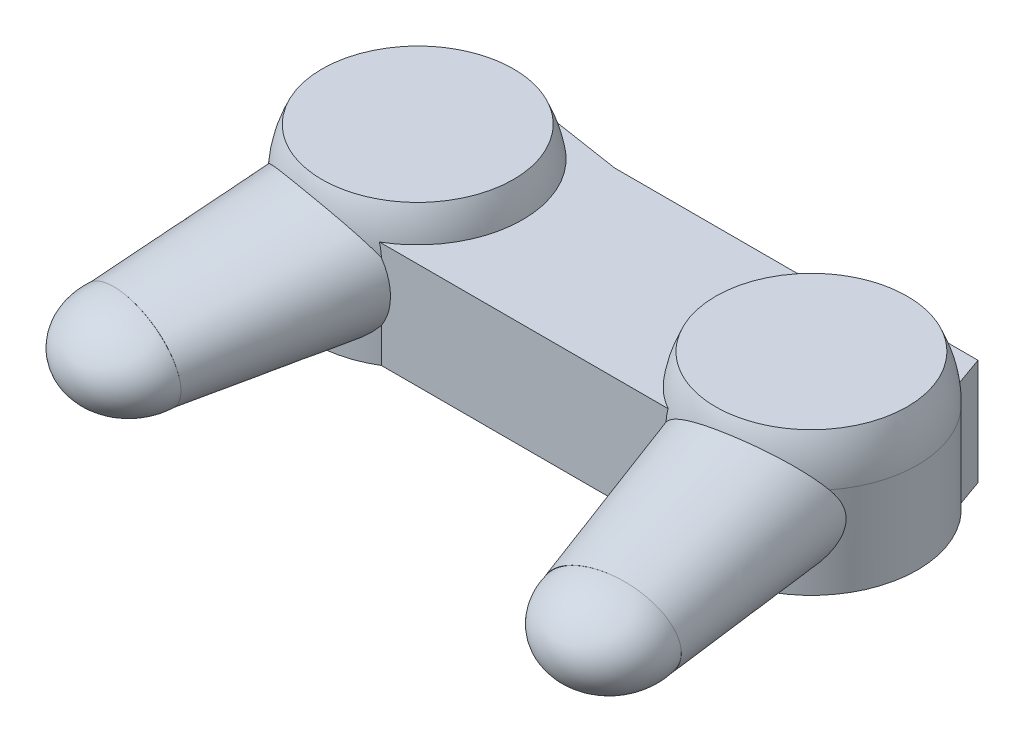
from build123d import *

# Parameters (mm, degrees)
BOSS_EXTRU_1_DEPTH      = 35
ESQUISSE2_R             = 35
BOSS_EXTRU_2_DEPTH      = 30
R_VOLUTION1_ANGLE       = 180
ENL_V_START             = -45
ESQUISSE4_R             = 35
ENL_V_MAT_EXTRU_1_DEPTH = 33
ESQUISSE6_RX            = 20
ESQUISSE6_RY            = 15.001744384
BOSS_EXTRU_3_DEPTH      = 70
BOSS_EXTRU_3_TAPER      = -6
R_VOLUTION2_ANGLE       = 180


with BuildPart() as part:
    # Esquisse1 → Boss.-Extru.1 (new body)
    with BuildSketch(Plane(origin=(0, 0, 0), x_dir=(1, 0, 0), z_dir=(0, 1, 0))):
        with BuildLine():
            Line((-30, 30), (-59.647058824, 34.588235294))
            ThreePointArc((-59.647058824, 34.588235294), (-62.315622539, 34.896906993), (-65, 35))
            Line((-65, 35), (-85, 35))
            Line((-85, 35), (-90, 20.857864376))
            Line((-90, 20.857864376), (-65, 0))
            Line((-65, 0), (-65, -30))
            Line((-65, -30), (0, -30))
            Line((0, -30), (0, 30))
            Line((0, 30), (-30, 30))
        make_face()
    extrude(amount=BOSS_EXTRU_1_DEPTH)

    # Esquisse2 → Boss.-Extru.2 (add)
    with BuildSketch(Plane(origin=(0, 0, 0), x_dir=(1, 0, 0), z_dir=(0, 1, 0))):
        with Locations((-65, 0)):
            Circle(ESQUISSE2_R)
    extrude(amount=BOSS_EXTRU_2_DEPTH)

    # Esquisse3 → Révolution1 (revolve)
    with BuildSketch(Plane(origin=(0, 30, 0), x_dir=(1, 0, 0), z_dir=(0, 1, 0))):
        with BuildLine():
            Line((-65, -35), (-65, 35))
            ThreePointArc((-65, 35), (-30, 0), (-65, -35))
        make_face()
    revolve(axis=Axis((-65, 30, 35), (0, 0, 1)), revolution_arc=R_VOLUTION1_ANGLE)

    # Esquisse4 → Enlèv. mat.-Extru.1 (cut)
    with BuildSketch(Plane.XZ.offset(ENL_V_START)):
        with Locations((-65, 0)):
            Circle(ESQUISSE4_R)
    extrude(amount=-ENL_V_MAT_EXTRU_1_DEPTH, mode=Mode.SUBTRACT)

    # Esquisse6 → Boss.-Extru.3 (add)
    with BuildSketch(Plane(origin=(-15.672844177, -9.645617247, 88.885116243), x_dir=(0.98441185, 0.015163049, 0.17522383), z_dir=(-0.172664972, -0.106264071, 0.979231716))):
        with Locations((-63.628392394, 25.673821893)):
            Ellipse(ESQUISSE6_RX, ESQUISSE6_RY)
    extrude(amount=-BOSS_EXTRU_3_DEPTH, taper=BOSS_EXTRU_3_TAPER)

    # Esquisse7 → Révolution2 (revolve)
    with BuildSketch(Plane(origin=(-15.672844177, -9.645617247, 88.885116243), x_dir=(0.984978067, -0.016367534, 0.17190204), z_dir=(-0.172664972, -0.106264071, 0.979231716))):
        with BuildLine():
            Line((-64.163509136, 8.645535086), (-64.657331191, 38.641470473))
            add(Edge.make_bspline(
                [(-64.163509136, 8.645535086), (-44.166218877, 8.974749789), (-44.413129905, 23.972717483), (-44.660040933, 38.970685177), (-64.657331191, 38.641470473)],
                knots=[1.570796327, 1.570796327, 1.570796327, 3.141592654, 3.141592654, 4.71238898, 4.71238898, 4.71238898], degree=2, weights=[1, 0.707106781, 1, 0.707106781, 1]))
        make_face()
    revolve(axis=Axis((-78.891854213, 0, 78.784620241), (0.018452562, -0.994337944, -0.104649681)), revolution_arc=R_VOLUTION2_ANGLE)

    # Symétrie3: part across plane


with BuildPart() as part_1:
    add(part.part)
    add(part.part.mirror(Plane(origin=(0, 35, -30), x_dir=(0, 0, 1), z_dir=(-1, 0, 0))))


solid = part_1.part
